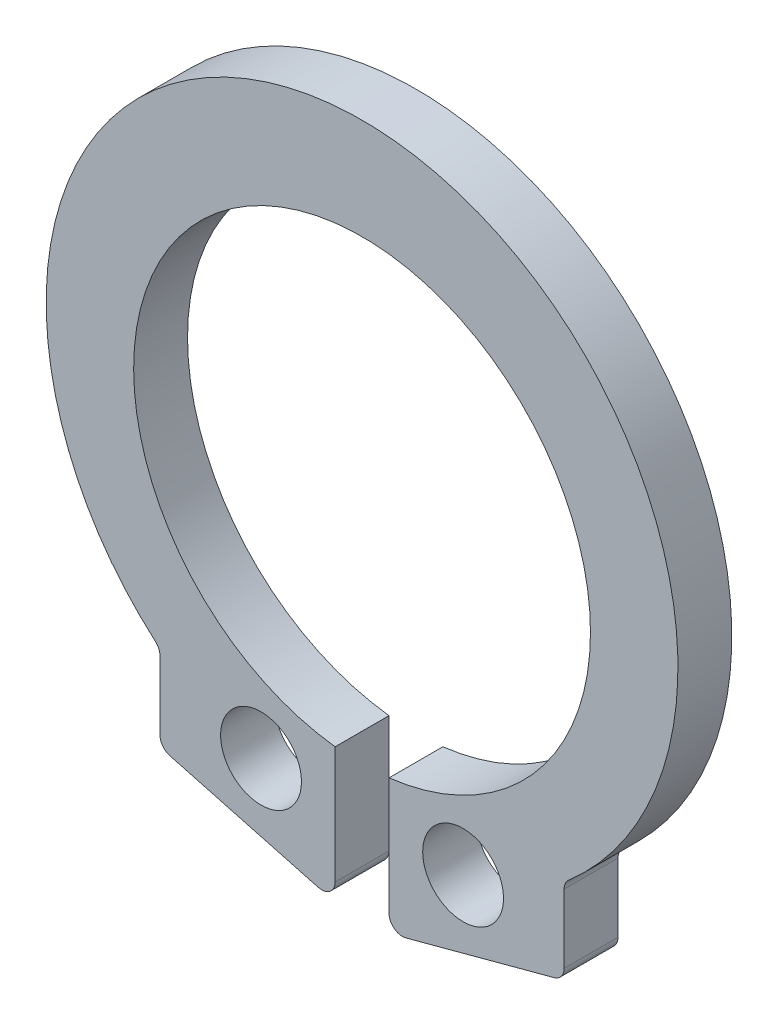
from build123d import *

# Parameters (mm, degrees)
SKETCH_1_R      = 0.6
EXTRUDE_1_DEPTH = 0.8
FILLET_1_R      = 0.2


with BuildPart() as part:
    # 草图1 → 凸台-拉伸1 (new body)
    with BuildSketch(Plane.XY):
        with BuildLine():
            Line((-0.4, -3.567629953), (-0.4, -5.567629953))
            Line((-0.4, -5.567629953), (-3, -4.870962053))
            Line((-3, -4.870962053), (-3, -3.605010402))
            ThreePointArc((-3, -3.605010402), (0, 4.69), (3, -3.605010402))
            Line((3, -3.605010402), (3, -4.870962053))
            Line((3, -4.870962053), (0.4, -5.567629953))
            Line((0.4, -5.567629953), (0.4, -3.567629953))
            ThreePointArc((0.4, -3.567629953), (0, 3.191302331), (-0.4, -3.567629953))
        make_face()
        with Locations((-1.5, -4.267629953)):
            Circle(SKETCH_1_R, mode=Mode.SUBTRACT)
        with Locations((1.5, -4.267629953)):
            Circle(SKETCH_1_R, mode=Mode.SUBTRACT)
    extrude(amount=EXTRUDE_1_DEPTH)

    # 圆角1
    fillet_1_edges = [part.edges().sort_by_distance(p)[0] for p in [
        (-0.4, -5.567629953, 0.4),
        (-3, -4.870962053, 0.4),
        (-3, -3.605010402, 0.4),
        (3, -3.605010402, 0.4),
        (3, -4.870962053, 0.4),
        (0.4, -5.567629953, 0.4),
    ]]
    fillet(fillet_1_edges, radius=FILLET_1_R)


solid = part.part
